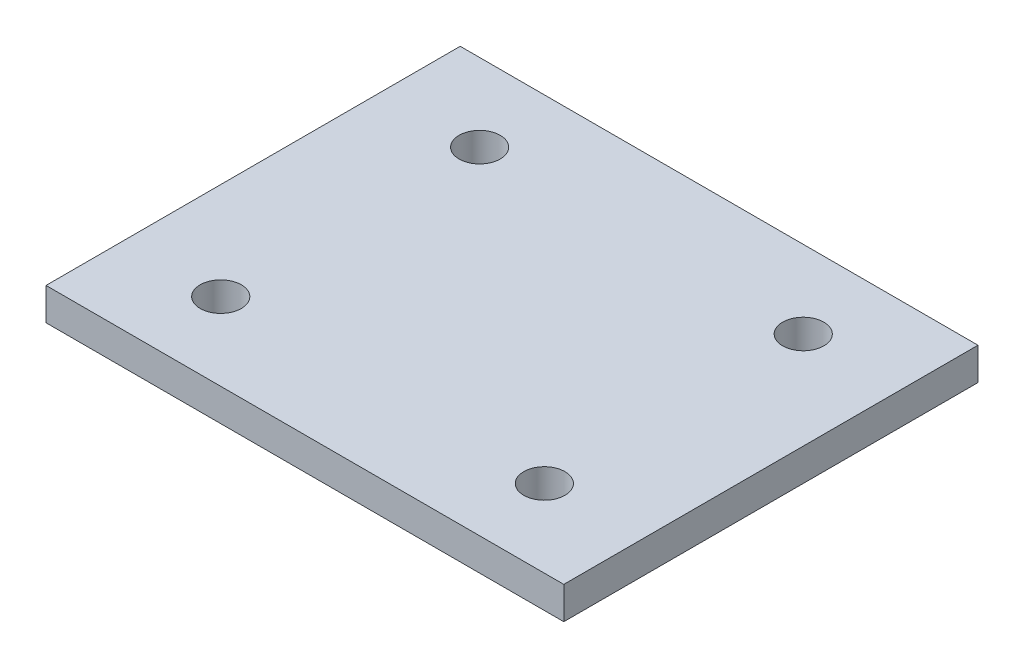
from build123d import *

# Parameters (mm, degrees)
SKETCH1_W           = 50.8
SKETCH1_H           = 40.64
SKETCH1_R           = 2.0193
BOSS_EXTRUDE1_DEPTH = 1.5875


with BuildPart() as part:
    # Sketch1 → Boss-Extrude1 (new body, symmetric)
    with BuildSketch(Plane(origin=(0, 0, 0), x_dir=(1, 0, 0), z_dir=(0, 1, 0))):
        Rectangle(SKETCH1_W, SKETCH1_H)
        with Locations((-15.875, 12.7)):
            Circle(SKETCH1_R, mode=Mode.SUBTRACT)
        with Locations((15.875, 12.7)):
            Circle(SKETCH1_R, mode=Mode.SUBTRACT)
        with Locations((15.875, -12.7)):
            Circle(SKETCH1_R, mode=Mode.SUBTRACT)
        with Locations((-15.875, -12.7)):
            Circle(SKETCH1_R, mode=Mode.SUBTRACT)
    extrude(amount=BOSS_EXTRUDE1_DEPTH, both=True)


solid = part.part
